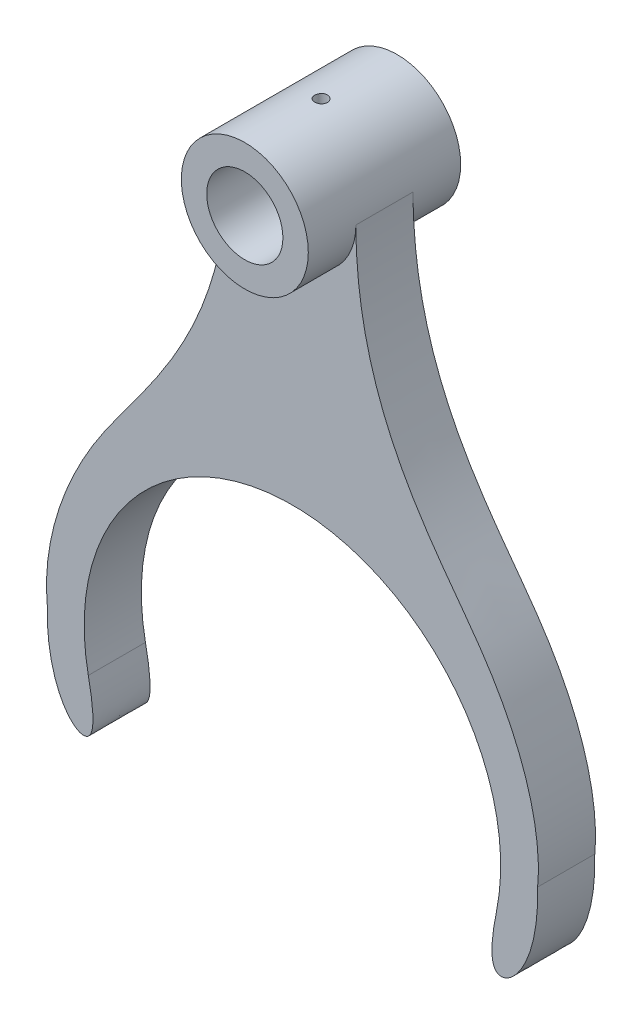
from build123d import *

# Parameters (mm, degrees)
BOSS_EXTRUDE1_DEPTH = 11.25
SKETCH1_3_R         = 25
SKETCH1_3_R_2       = 15
BOSS_EXTRUDE2_DEPTH = 30
SKETCH3_R           = 2.5
CUT_EXTRUDE1_DEPTH  = 36


with BuildPart() as part:
    # Sketch1 → Boss-Extrude1 (new body, symmetric)
    with BuildSketch(Plane.XY):
        with BuildLine():
            ThreePointArc((-80.369346148, -16.271699348), (0, 82), (80.369346148, -16.271699348))
            add(Edge.make_bspline(
                [(96.539745155, 0), (97.326558939, -29.331535134), (77.473492013, -47.573942745), (78.112479352, -27.418839229), (80.369346148, -16.271699348)],
                knots=[0, 0, 0, 0, 0.663724029, 1, 1, 1, 1], degree=3))
            add(Edge.make_bspline(
                [(96.539745155, 0), (96.493331912, 1.730233625), (104.346209234, 48.769492673), (25, 126.848420751), (25, 190)],
                knots=[0, 0, 0, 0, 0.598565743, 1, 1, 1, 1], degree=3))
            ThreePointArc((25, 190), (0, 165), (-25, 190))
            add(Edge.make_bspline(
                [(-96.539745155, 0), (-96.493331912, 1.730233625), (-104.346209234, 48.769492673), (-25, 126.848420751), (-25, 190)],
                knots=[0, 0, 0, 0, 0.598565743, 1, 1, 1, 1], degree=3))
            add(Edge.make_bspline(
                [(-96.539745155, 0), (-97.326558939, -29.331535134), (-77.473492013, -47.573942745), (-78.112479352, -27.418839229), (-80.369346148, -16.271699348)],
                knots=[0, 0, 0, 0, 0.663724029, 1, 1, 1, 1], degree=3))
        make_face()
    extrude(amount=BOSS_EXTRUDE1_DEPTH, both=True)

    # Sketch1_3 → Boss-Extrude2 (add, symmetric)
    with BuildSketch(Plane.XY):
        with Locations((0, 190)):
            Circle(SKETCH1_3_R)
        with Locations((0, 190)):
            Circle(SKETCH1_3_R_2, mode=Mode.SUBTRACT)
    extrude(amount=BOSS_EXTRUDE2_DEPTH, both=True)

    # Sketch3 → Cut-Extrude1 (cut, through all)
    with BuildSketch(Plane(origin=(0, 180, 0), x_dir=(1, 0, 0), z_dir=(0, 1, 0))):
        Circle(SKETCH3_R)
    extrude(amount=CUT_EXTRUDE1_DEPTH, mode=Mode.SUBTRACT)


solid = part.part
